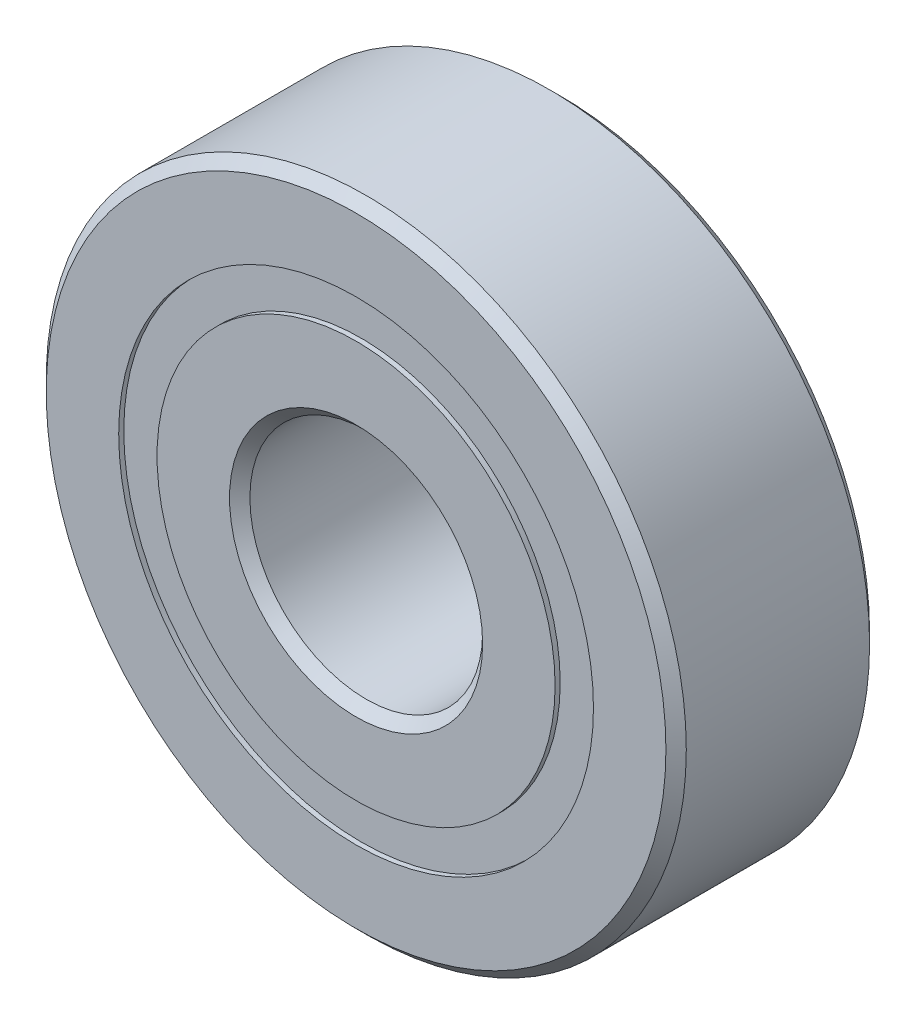
from build123d import *

# Parameters (mm, degrees)
CIRPATTERN1_COUNT = 12
SKETCH5_W         = 1.635478413
SKETCH5_H         = 1.318681318


with BuildPart() as part:
    # Sketch1 → Revolve1 (revolve)
    with BuildSketch(Plane(origin=(0, 0, 0), x_dir=(0, 0, -1), z_dir=(1, 0, 0))):
        with BuildLine():
            Line((3.15, 11), (-3.15, 11))
            Line((-3.15, 11), (-3.5, 10.65))
            Line((-3.5, 10.65), (-3.5, 8.159340659))
            Line((-3.5, 8.159340659), (-1.555555556, 8.159340659))
            ThreePointArc((-1.555555556, 8.159340659), (0, 9.189521587), (1.555555556, 8.159340659))
            Line((1.555555556, 8.159340659), (3.5, 8.159340659))
            Line((3.5, 8.159340659), (3.5, 10.65))
            Line((3.5, 10.65), (3.15, 11))
        make_face()
    revolve(axis=Axis((0, 0, 3.5), (0, 0, -1)))


with BuildPart() as body_2:
    # Sketch3 → Revolve3 (revolve)
    with BuildSketch(Plane(origin=(0, 0, 0), x_dir=(0, 0, -1), z_dir=(1, 0, 0))):
        with BuildLine():
            Line((-3.5, 6.840659341), (-1.555555556, 6.840659341))
            ThreePointArc((-1.555555556, 6.840659341), (0, 5.810478413), (1.555555556, 6.840659341))
            Line((1.555555556, 6.840659341), (3.5, 6.840659341))
            Line((3.5, 6.840659341), (3.5, 4.35))
            Line((3.5, 4.35), (3.15, 4))
            Line((3.15, 4), (-3.15, 4))
            Line((-3.15, 4), (-3.5, 4.35))
            Line((-3.5, 4.35), (-3.5, 6.840659341))
        make_face()
    revolve(axis=Axis((0, 0, 3.5), (0, 0, -1)))


with BuildPart() as body_3:
    # Sketch4 → Revolve4 (revolve)
    with BuildSketch(Plane(origin=(0, 0, 0), x_dir=(0, 0, -1), z_dir=(1, 0, 0))):
        with BuildLine():
            Line((-1.689521587, 7.5), (1.689521587, 7.5))
            ThreePointArc((1.689521587, 7.5), (0, 9.189521587), (-1.689521587, 7.5))
        make_face()
    revolve(axis=Axis((0, 7.5, 1.689521587), (0, 0, -1)))


with BuildPart() as cirpattern1_1:
    # CirPattern1: pattern copy
    add(body_3.part.rotate(Axis((0, 0, 0), (0, 0, 1)), 1 * 360 / CIRPATTERN1_COUNT))


with BuildPart() as cirpattern1_2:
    # CirPattern1: pattern copy
    add(body_3.part.rotate(Axis((0, 0, 0), (0, 0, 1)), 2 * 360 / CIRPATTERN1_COUNT))


with BuildPart() as cirpattern1_3:
    # CirPattern1: pattern copy
    add(body_3.part.rotate(Axis((0, 0, 0), (0, 0, 1)), 3 * 360 / CIRPATTERN1_COUNT))


with BuildPart() as cirpattern1_4:
    # CirPattern1: pattern copy
    add(body_3.part.rotate(Axis((0, 0, 0), (0, 0, 1)), 4 * 360 / CIRPATTERN1_COUNT))


with BuildPart() as cirpattern1_5:
    # CirPattern1: pattern copy
    add(body_3.part.rotate(Axis((0, 0, 0), (0, 0, 1)), 5 * 360 / CIRPATTERN1_COUNT))


with BuildPart() as cirpattern1_6:
    # CirPattern1: pattern copy
    add(body_3.part.rotate(Axis((0, 0, 0), (0, 0, 1)), 6 * 360 / CIRPATTERN1_COUNT))


with BuildPart() as cirpattern1_7:
    # CirPattern1: pattern copy
    add(body_3.part.rotate(Axis((0, 0, 0), (0, 0, 1)), 7 * 360 / CIRPATTERN1_COUNT))


with BuildPart() as cirpattern1_8:
    # CirPattern1: pattern copy
    add(body_3.part.rotate(Axis((0, 0, 0), (0, 0, 1)), 8 * 360 / CIRPATTERN1_COUNT))


with BuildPart() as cirpattern1_9:
    # CirPattern1: pattern copy
    add(body_3.part.rotate(Axis((0, 0, 0), (0, 0, 1)), 9 * 360 / CIRPATTERN1_COUNT))


with BuildPart() as cirpattern1_10:
    # CirPattern1: pattern copy
    add(body_3.part.rotate(Axis((0, 0, 0), (0, 0, 1)), 10 * 360 / CIRPATTERN1_COUNT))


with BuildPart() as cirpattern1_11:
    # CirPattern1: pattern copy
    add(body_3.part.rotate(Axis((0, 0, 0), (0, 0, 1)), 11 * 360 / CIRPATTERN1_COUNT))


with BuildPart() as body_15:
    # Sketch5 → Revolve5 (revolve)
    with BuildSketch(Plane(origin=(0, 0, 0), x_dir=(0, 0, -1), z_dir=(1, 0, 0))):
        with Locations((-2.507260794, 7.5)):
            Rectangle(SKETCH5_W, SKETCH5_H)
        with Locations((2.507260794, 7.5)):
            Rectangle(SKETCH5_W, SKETCH5_H)
    revolve(axis=Axis((0, 0, 3.5), (0, 0, -1)))


solid = Compound([part.part, body_2.part, body_3.part, cirpattern1_1.part, cirpattern1_2.part, cirpattern1_3.part, cirpattern1_4.part, cirpattern1_5.part, cirpattern1_6.part, cirpattern1_7.part, cirpattern1_8.part, cirpattern1_9.part, cirpattern1_10.part, cirpattern1_11.part, body_15.part])
